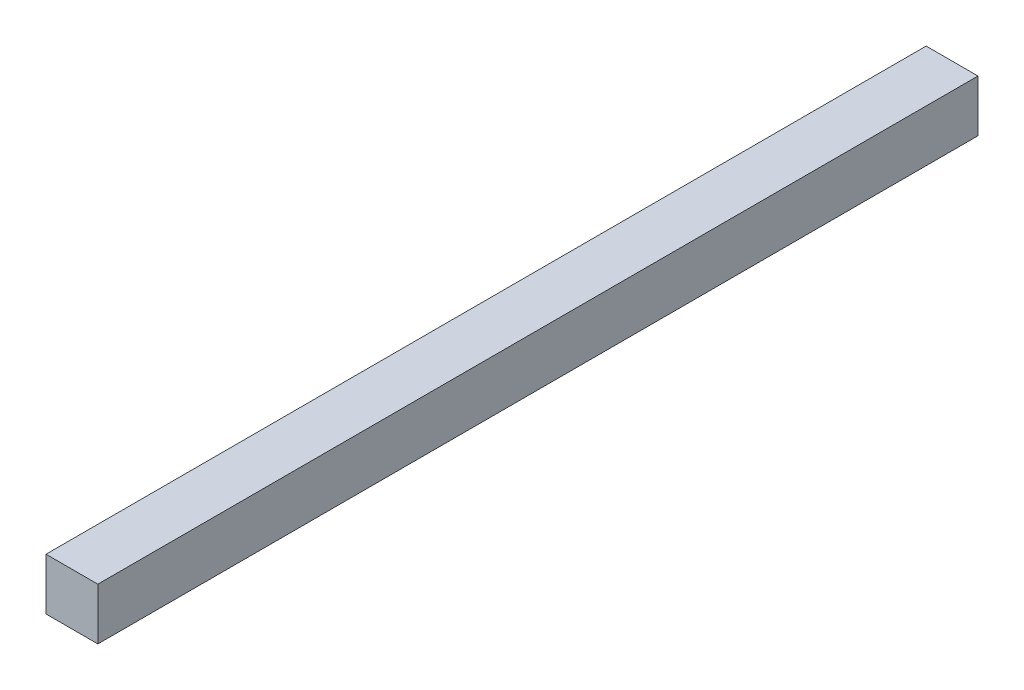
from build123d import *

# Parameters (mm, degrees)
ESBO_O2_W                = 30.045415171
ESBO_O2_H                = 30
RESSALTO_EXTRUS_O1_DEPTH = 255


with BuildPart() as part:
    # Esboço2 → Ressalto-extrusão1 (new body, symmetric)
    with BuildSketch(Plane.XY):
        with Locations((-95.635568537, 15)):
            Rectangle(ESBO_O2_W, ESBO_O2_H)
    extrude(amount=RESSALTO_EXTRUS_O1_DEPTH, both=True)


solid = part.part
